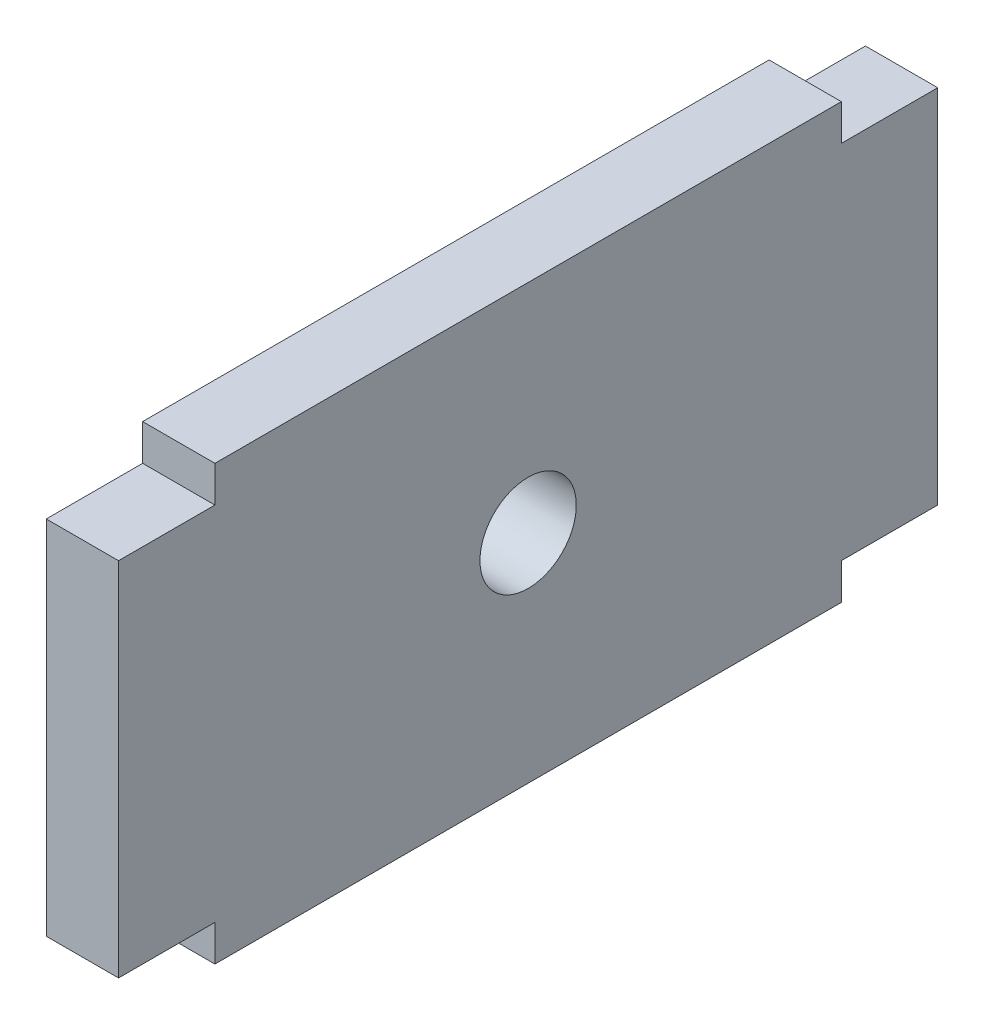
from build123d import *

# Parameters (mm, degrees)
BOSS_EXTRUDE1_DEPTH = 3
SKETCH2_R           = 2
CUT_EXTRUDE1_DEPTH  = 3


with BuildPart() as part:
    # Sketch1 → Boss-Extrude1 (new body)
    with BuildSketch(Plane(origin=(0, 0, 0), x_dir=(0, 0, -1), z_dir=(1, 0, 0))):
        Polygon((-9.832231839, 2.423101367), (-13.832231839, 2.423101367), (-13.832231839, -12.576898633), (-9.832231839, -12.576898633), (-9.832231839, -14.076898633), (16.167768161, -14.076898633), (16.167768161, -12.576898633), (20.167768161, -12.576898633), (20.167768161, 2.423101367), (16.167768161, 2.423101367), (16.167768161, 3.923101367), (-9.832231839, 3.923101367), align=None)
    extrude(amount=BOSS_EXTRUDE1_DEPTH)

    # Sketch2 → Cut-Extrude1 (cut)
    with BuildSketch(Plane.ZY):
        with Locations((-3.167768161, -5.076898633)):
            Circle(SKETCH2_R)
    extrude(amount=-CUT_EXTRUDE1_DEPTH, mode=Mode.SUBTRACT)


solid = part.part
